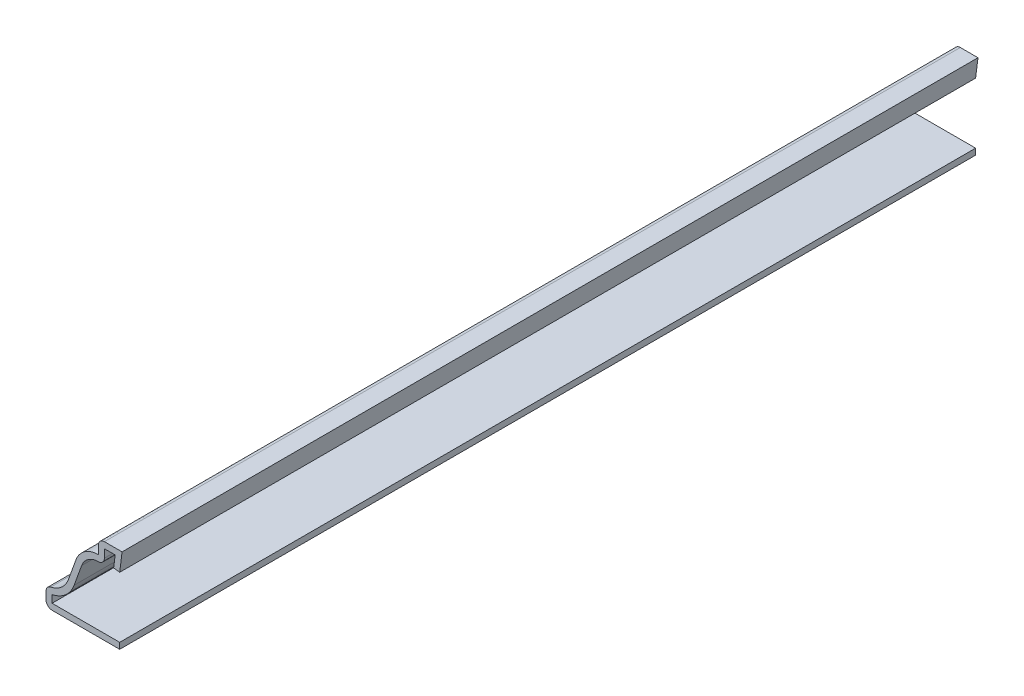
from build123d import *

# Parameters (mm, degrees)
EXTRUDE_THIN1_DEPTH = 142.875
FILLET1_R           = 1.016


with BuildPart() as part:
    # Sketch1 → Extrude-Thin1 (new body)
    with BuildSketch(Plane.XY):
        with BuildLine():
            Line((-0.396875, 0), (-12.7, 0))
            Line((-12.7, 0), (-12.7, 3.175))
            ThreePointArc((-12.7, 3.175), (-10.421749313, 3.894049957), (-8.969036168, 5.790647844))
            Line((-8.969036168, 5.790647844), (-7.699713832, 9.290602156))
            ThreePointArc((-7.699713832, 9.290602156), (-6.247000687, 11.187200043), (-3.96875, 11.90625))
            Line((-3.96875, 11.90625), (-3.96875, 14.2875))
            Line((-3.96875, 14.2875), (0, 14.2875))
            Line((0, 14.2875), (-0.396875, 11.137402345))
            Line((-0.396875, 11.137402345), (-1.40490625, 11.264402345))
            Line((-1.40490625, 11.264402345), (-1.152035714, 13.2715))
            Line((-1.152035714, 13.2715), (-2.95275, 13.2715))
            Line((-2.95275, 13.2715), (-2.95275, 10.70994956))
            ThreePointArc((-2.95275, 10.70994956), (-5.215232033, 10.614254584), (-6.744587091, 8.944208004))
            Line((-6.744587091, 8.944208004), (-8.013909427, 5.444253692))
            ThreePointArc((-8.013909427, 5.444253692), (-9.435411883, 3.376762213), (-11.684, 2.263639698))
            Line((-11.684, 2.263639698), (-11.684, 1.016))
            Line((-11.684, 1.016), (-0.396875, 1.016))
            Line((-0.396875, 1.016), (-0.396875, 0))
        make_face()
    extrude(amount=-EXTRUDE_THIN1_DEPTH)

    # Fillet1
    fillet1_edges = [part.edges().sort_by_distance(p)[0] for p in [
        (-2.95275, 10.70994956, -71.4375),
        (-12.7, 0, -71.4375),
        (-12.7, 3.175, -71.4375),
        (-3.96875, 14.2875, -71.4375),
    ]]
    fillet(fillet1_edges, radius=FILLET1_R)


solid = part.part
